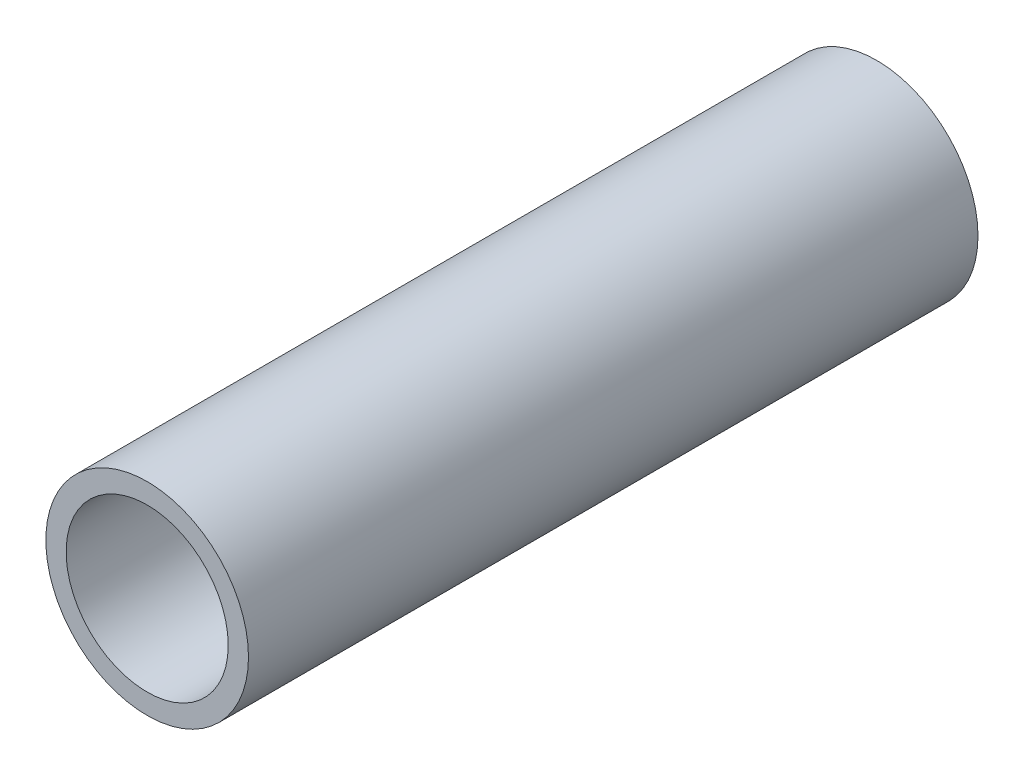
from build123d import *

# Parameters (mm, degrees)
SKETCH1_R           = 1.25
SKETCH1_R_2         = 1
TUBE_DIP_BODY_DEPTH = 9


with BuildPart() as part:
    # Sketch1 → Tube DIP Body (new body)
    with BuildSketch(Plane.XY):
        Circle(SKETCH1_R)
        Circle(SKETCH1_R_2, mode=Mode.SUBTRACT)
    extrude(amount=TUBE_DIP_BODY_DEPTH)


solid = part.part
